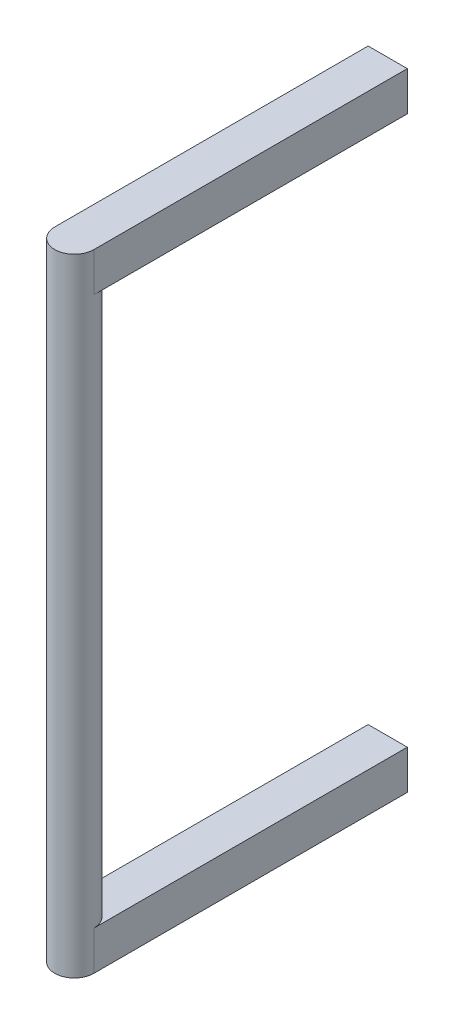
from build123d import *

# Parameters (mm, degrees)
SKETCH1_R           = 12.7
BOSS_EXTRUDE1_DEPTH = 177.8
BOSS_EXTRUDE2_DEPTH = 25.4


with BuildPart() as part:
    # Sketch1 → Boss-Extrude1 (new body)
    with BuildSketch(Plane(origin=(0, 0, 0), x_dir=(1, 0, 0), z_dir=(0, 1, 0))):
        Circle(SKETCH1_R)
    boss_extrude1 = extrude(amount=BOSS_EXTRUDE1_DEPTH)

    # Sketch2 → Boss-Extrude2 (add)
    with BuildSketch(Plane(origin=(0, 177.8, 0), x_dir=(1, 0, 0), z_dir=(0, 1, 0))):
        with BuildLine():
            Line((-12.7, 0), (-12.7, 203.2))
            Line((-12.7, 203.2), (12.7, 203.2))
            Line((12.7, 203.2), (12.7, 0))
            ThreePointArc((12.7, 0), (0, -12.7), (-12.7, 0))
        make_face()
    boss_extrude2 = extrude(amount=BOSS_EXTRUDE2_DEPTH)

    # Mirror1: Boss-Extrude1, Boss-Extrude2 across plane
    add(boss_extrude1.mirror(Plane(origin=(0, 0, 0), x_dir=(0, 0, 1), z_dir=(0, -1, 0))))
    add(boss_extrude2.mirror(Plane(origin=(0, 0, 0), x_dir=(0, 0, 1), z_dir=(0, -1, 0))))


solid = part.part
